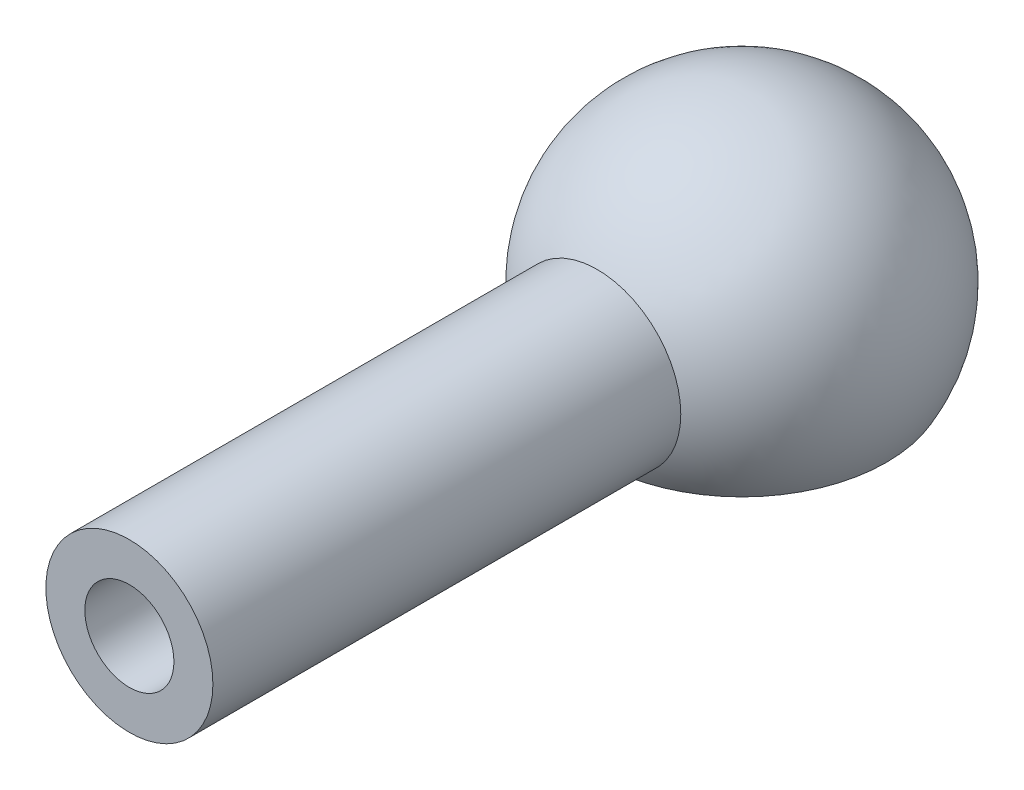
from build123d import *

# Parameters (mm, degrees)
SKETCH2_R                       = 1.875
BOSS_EXTRUDE1_DEPTH             = 10
BOSS_EXTRUDE1_DIRECTION_2_REACH = 9.5
SKETCH5_R                       = 1
CUT_EXTRUDE1_DEPTH              = 10


with BuildPart() as part:
    # Sketch1 → Revolve1 (revolve)
    with BuildSketch(Plane.XY):
        with BuildLine():
            Line((-3.247595264, -1.875), (-2.165063509, -1.25))
            ThreePointArc((-2.165063509, -1.25), (-2.165063509, 1.25), (0, 2.5))
            Line((0, 2.5), (0, 3.75))
            ThreePointArc((0, 3.75), (-3.247595264, 1.875), (-3.247595264, -1.875))
        make_face()
    revolve(axis=Axis((0, 2.5, 0), (0, 1, 0)))

    # Sketch2 → Boss-Extrude1 (add)
    with BuildSketch(Plane.XY.offset(3.75)):
        Circle(SKETCH2_R)
    extrude(amount=BOSS_EXTRUDE1_DEPTH)

    # Sketch2 → Boss-Extrude1 direction 2 (add, up to next)
    with BuildSketch(Plane.XY.offset(3.75), mode=Mode.PRIVATE) as boss_extrude1_direction_2_sk1:
        Circle(SKETCH2_R)
    boss_extrude1_direction_2_tool1 = extrude(boss_extrude1_direction_2_sk1.sketch, amount=-BOSS_EXTRUDE1_DIRECTION_2_REACH, mode=Mode.PRIVATE) - part.part
    add(boss_extrude1_direction_2_tool1.solids().sort_by_distance((0, 0, 3.75))[0])

    # Sketch5 → Cut-Extrude1 (cut)
    with BuildSketch(Plane.XY.offset(13.75)):
        Circle(SKETCH5_R)
    extrude(amount=-CUT_EXTRUDE1_DEPTH, mode=Mode.SUBTRACT)


solid = part.part
